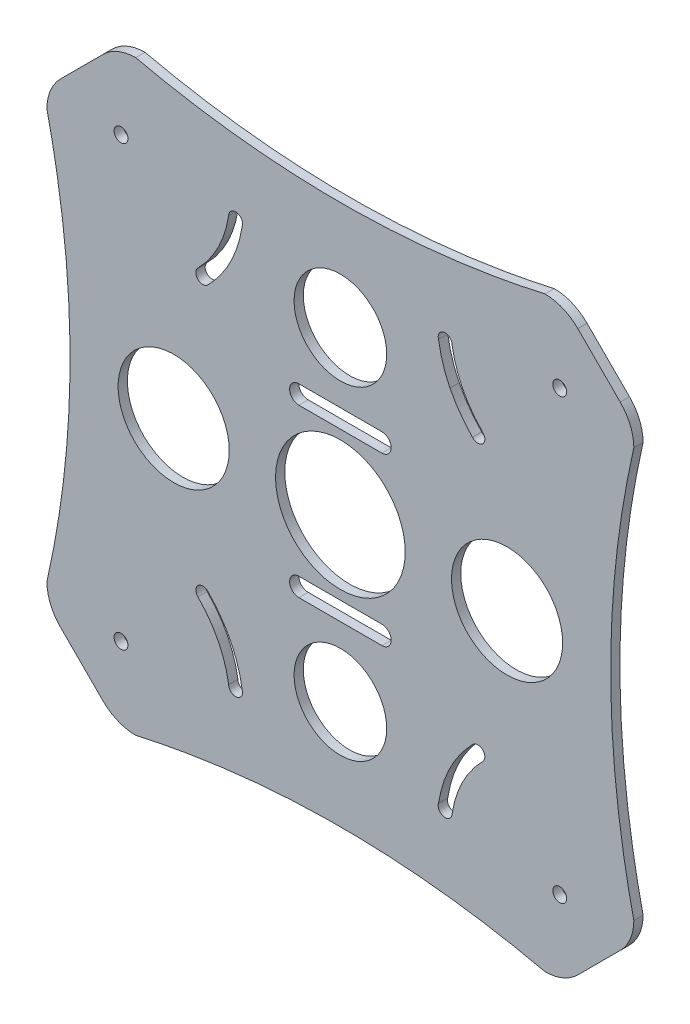
from build123d import *

# Parameters (mm, degrees)
SKETCH1_R           = 1.5
BOSS_EXTRUDE1_DEPTH = 2
SKETCH4_R           = 14
SKETCH4_R_2         = 12
SKETCH4_R_3         = 10
CUT_EXTRUDE1_DEPTH  = 10


with BuildPart() as part:
    # Sketch1 → Boss-Extrude1 (new body)
    with BuildSketch(Plane.XY):
        with BuildLine():
            Line((60.447222151, 51.275649276), (51.275649276, 60.447222151))
            ThreePointArc((51.275649276, 60.447222151), (48.031415788, 62.614949665), (44.204581464, 63.376154339))
            add(Edge.make_bspline(
                [(-44.204581464, 63.376154339), (0, 53.376154339), (44.204581464, 63.376154339)],
                knots=[0, 0, 0, 1, 1, 1], degree=2))
            ThreePointArc((-44.204581464, 63.376154339), (-48.031415788, 62.614949665), (-51.275649276, 60.447222151))
            Line((-51.275649276, 60.447222151), (-60.447222151, 51.275649276))
            ThreePointArc((-60.447222151, 51.275649276), (-62.614949665, 48.031415788), (-63.376154339, 44.204581464))
            add(Edge.make_bspline(
                [(-63.376154339, -44.204581464), (-53.376154339, 0), (-63.376154339, 44.204581464)],
                knots=[0, 0, 0, 1, 1, 1], degree=2))
            ThreePointArc((-63.376154339, -44.204581464), (-62.614949665, -48.031415788), (-60.447222151, -51.275649276))
            Line((-60.447222151, -51.275649276), (-51.275649276, -60.447222151))
            ThreePointArc((-51.275649276, -60.447222151), (-48.031415788, -62.614949665), (-44.204581464, -63.376154339))
            add(Edge.make_bspline(
                [(44.204581464, -63.376154339), (0, -53.376154339), (-44.204581464, -63.376154339)],
                knots=[0, 0, 0, 1, 1, 1], degree=2))
            ThreePointArc((44.204581464, -63.376154339), (48.031415788, -62.614949665), (51.275649276, -60.447222151))
            Line((51.275649276, -60.447222151), (60.447222151, -51.275649276))
            ThreePointArc((60.447222151, -51.275649276), (62.614949665, -48.031415788), (63.376154339, -44.204581464))
            add(Edge.make_bspline(
                [(63.376154339, 44.204581464), (53.376154339, 0), (63.376154339, -44.204581464)],
                knots=[0, 0, 0, 1, 1, 1], degree=2))
            ThreePointArc((63.376154339, 44.204581464), (62.614949665, 48.031415788), (60.447222151, 51.275649276))
        make_face()
        with Locations((-47.376154339, -47.37615434)):
            Circle(SKETCH1_R, mode=Mode.SUBTRACT)
        with BuildLine():
            ThreePointArc((-28.761031711, -28.527510136), (-28.631586297, -28.644099888), (-28.51653182, -28.774911786))
            add(Edge.make_bspline(
                [(-21.191797917, -43.405881611), (-22.512426592, -34.921752495), (-28.516531822, -28.774911788)],
                knots=[0.024414386, 0.024414386, 0.024414386, 0.9806816, 0.9806816, 0.9806816], degree=2))
            ThreePointArc((-21.191797914, -43.40588161), (-21.143599518, -43.62088039), (-21.127416998, -43.840620434))
            ThreePointArc((-21.127416998, -43.840620434), (-22.627416998, -45.340620434), (-24.127416998, -43.840620434))
            add(Edge.make_bspline(
                [(-24.127416998, -43.840620434), (-25.362407372, -36.251653189), (-30.759144982, -30.759144982)],
                knots=[0, 0, 0, 1, 1, 1], degree=2))
            ThreePointArc((-30.759144982, -30.759144982), (-30.816001484, -28.697906735), (-28.761031711, -28.527510136))
        make_face(mode=Mode.SUBTRACT)
        with BuildLine():
            add(Edge.make_bspline(
                [(24.127416998, -43.840620434), (25.362407372, -36.251653189), (30.759144982, -30.759144982)],
                knots=[0, 0, 0, 1, 1, 1], degree=2))
            ThreePointArc((24.127416998, -43.840620434), (22.627416998, -45.340620434), (21.127416998, -43.840620434))
            ThreePointArc((21.127416998, -43.840620434), (21.143599518, -43.62088039), (21.191797914, -43.40588161))
            add(Edge.make_bspline(
                [(21.191797917, -43.405881611), (22.512426592, -34.921752495), (28.516531822, -28.774911788)],
                knots=[0.024414386, 0.024414386, 0.024414386, 0.9806816, 0.9806816, 0.9806816], degree=2))
            ThreePointArc((28.51653182, -28.774911786), (28.631586297, -28.644099888), (28.761031711, -28.527510136))
            ThreePointArc((28.761031711, -28.527510136), (30.816001484, -28.697906735), (30.759144982, -30.759144982))
        make_face(mode=Mode.SUBTRACT)
        with Locations((47.376154339, -47.376154339)):
            Circle(SKETCH1_R, mode=Mode.SUBTRACT)
        with Locations((-47.376154339, 47.376154339)):
            Circle(SKETCH1_R, mode=Mode.SUBTRACT)
        with BuildLine():
            add(Edge.make_bspline(
                [(-24.127416998, 43.840620434), (-25.362407372, 36.251653189), (-30.759144982, 30.759144982)],
                knots=[0, 0, 0, 1, 1, 1], degree=2))
            ThreePointArc((-24.127416998, 43.840620434), (-22.627416998, 45.340620434), (-21.127416998, 43.840620434))
            ThreePointArc((-21.127416998, 43.840620434), (-21.143599518, 43.62088039), (-21.191797914, 43.40588161))
            add(Edge.make_bspline(
                [(-21.191797917, 43.405881611), (-22.512426592, 34.921752495), (-28.516531822, 28.774911788)],
                knots=[0.024414386, 0.024414386, 0.024414386, 0.9806816, 0.9806816, 0.9806816], degree=2))
            ThreePointArc((-28.51653182, 28.774911786), (-28.631586297, 28.644099888), (-28.761031711, 28.527510136))
            ThreePointArc((-28.761031711, 28.527510136), (-30.816001484, 28.697906735), (-30.759144982, 30.759144982))
        make_face(mode=Mode.SUBTRACT)
        with BuildLine():
            ThreePointArc((28.761031711, 28.527510136), (28.631586297, 28.644099888), (28.51653182, 28.774911786))
            add(Edge.make_bspline(
                [(23.673604803, 35.525452482), (25.506528794, 31.856471559), (28.516531822, 28.774911788)],
                knots=[0.501281739, 0.501281739, 0.501281739, 0.9806816, 0.9806816, 0.9806816], degree=2))
            add(Edge.make_bspline(
                [(21.191797917, 43.405881611), (21.850363527, 39.175051421), (23.673604803, 35.525452482)],
                knots=[0.024414386, 0.024414386, 0.024414386, 0.501281739, 0.501281739, 0.501281739], degree=2))
            ThreePointArc((21.191797914, 43.40588161), (21.143599518, 43.62088039), (21.127416998, 43.840620434))
            ThreePointArc((21.127416998, 43.840620434), (22.627416998, 45.340620434), (24.127416998, 43.840620434))
            add(Edge.make_bspline(
                [(24.127416998, 43.840620434), (24.734971072, 40.107224563), (26.349731434, 36.881203745)],
                knots=[0, 0, 0, 0.491950453, 0.491950453, 0.491950453], degree=2))
            ThreePointArc((26.349731434, 36.881203745), (26.356395509, 36.86807251), (26.362930356, 36.854876488))
            add(Edge.make_bspline(
                [(26.362930356, 36.854876488), (28.028171669, 33.538582193), (30.759144982, 30.759144982)],
                knots=[0.493958478, 0.493958478, 0.493958478, 1, 1, 1], degree=2))
            ThreePointArc((30.759144982, 30.759144982), (30.816001484, 28.697906735), (28.761031711, 28.527510136))
        make_face(mode=Mode.SUBTRACT)
        with Locations((47.376154339, 47.376154339)):
            Circle(SKETCH1_R, mode=Mode.SUBTRACT)
    extrude(amount=BOSS_EXTRUDE1_DEPTH)

    # Sketch4 → Cut-Extrude1 (cut)
    with BuildSketch(Plane(origin=(0, 0, 0), x_dir=(-1, 0, 0), z_dir=(0, 0, -1))):
        Circle(SKETCH4_R)
        with Locations((-36, 0)):
            Circle(SKETCH4_R_2)
        with Locations((36, 0)):
            Circle(SKETCH4_R_2)
        with Locations((0, 35)):
            Circle(SKETCH4_R_3)
        with Locations((0, -35)):
            Circle(SKETCH4_R_3)
        with BuildLine():
            Line((-8.965692962, 20), (8.965692962, 20))
            ThreePointArc((8.965692962, 20), (10.965692962, 18), (8.965692962, 16))
            Line((8.965692962, 16), (-8.965692962, 16))
            ThreePointArc((-8.965692962, 16), (-10.965692962, 18), (-8.965692962, 20))
        make_face()
        with BuildLine():
            Line((8.965692962, -20), (-8.965692962, -20))
            ThreePointArc((-8.965692962, -20), (-10.965692962, -18), (-8.965692962, -16))
            Line((-8.965692962, -16), (8.965692962, -16))
            ThreePointArc((8.965692962, -16), (10.965692962, -18), (8.965692962, -20))
        make_face()
    extrude(amount=-CUT_EXTRUDE1_DEPTH, mode=Mode.SUBTRACT)


solid = part.part
